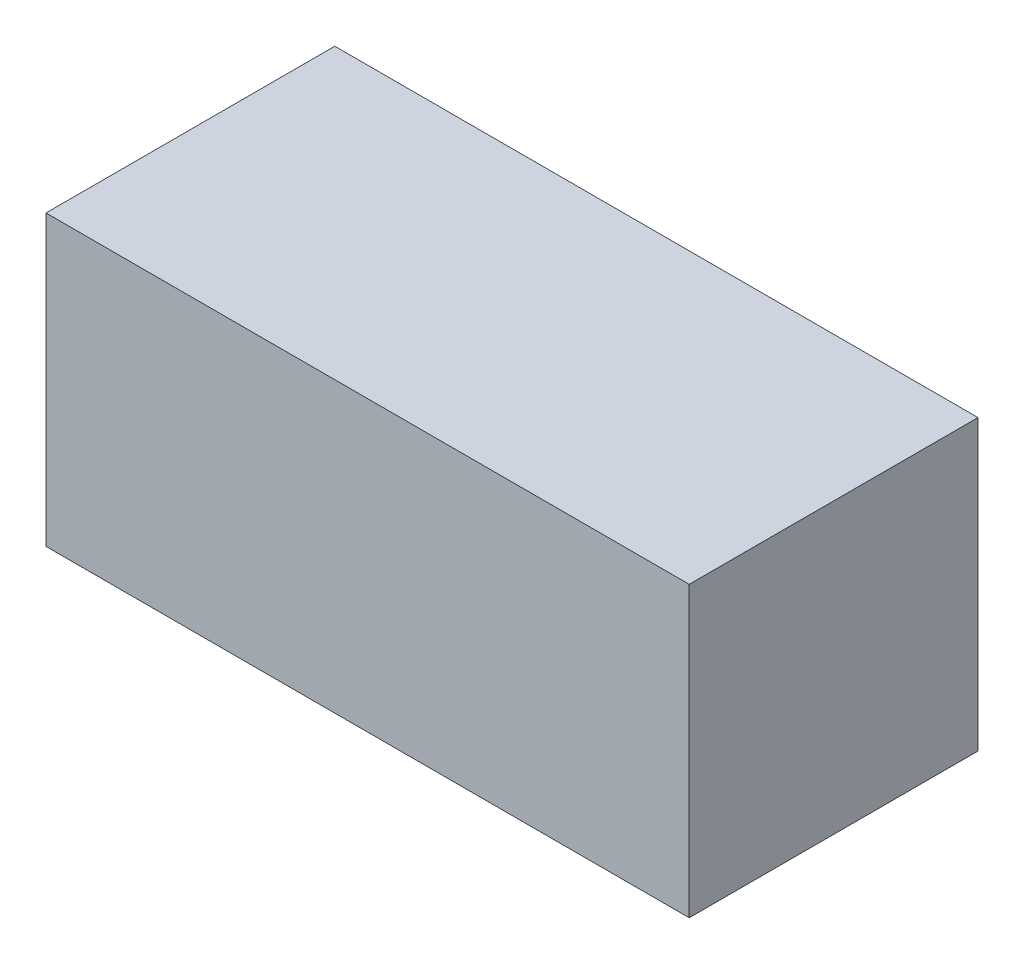
from build123d import *

# Parameters (mm, degrees)
SKETCH1_W           = 4900
SKETCH1_H           = 2200
BOSS_EXTRUDE1_DEPTH = 2200


with BuildPart() as part:
    # Sketch1 → Boss-Extrude1 (new body)
    with BuildSketch(Plane(origin=(0, 0, 0), x_dir=(1, 0, 0), z_dir=(0, 1, 0))):
        Rectangle(SKETCH1_W, SKETCH1_H)
    extrude(amount=BOSS_EXTRUDE1_DEPTH)


solid = part.part
